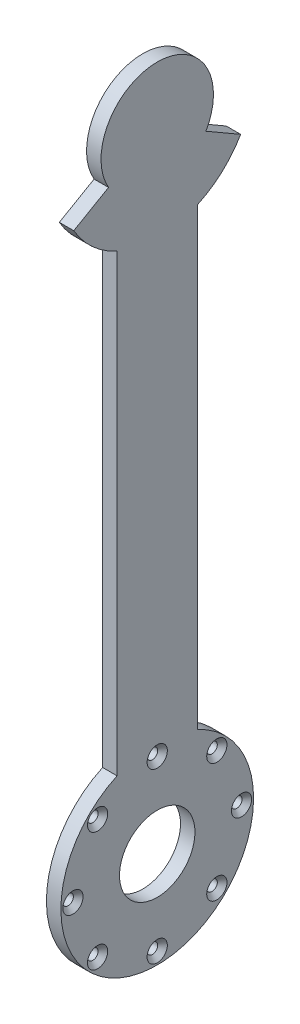
from build123d import *

# Parameters (mm, degrees)
SKETCH1_R                                           = 23.5
BOSS_EXTRUDE1_DEPTH                                 = 9
CSK_FOR_M6_COUNTERSUNK_FLAT_HEAD_SCREW1_D           = 6.6
CSK_FOR_M6_COUNTERSUNK_FLAT_HEAD_SCREW1_CSINK_D     = 12.6
CSK_FOR_M6_COUNTERSUNK_FLAT_HEAD_SCREW1_CSINK_ANGLE = 90


with BuildPart() as part:
    # Sketch1 → Boss-Extrude1 (new body)
    with BuildSketch(Plane(origin=(0, 0, 0), x_dir=(0, 0, -1), z_dir=(1, 0, 0))):
        with BuildLine():
            Line((-30.310889132, 178.5), (-51.961524227, 166))
            ThreePointArc((-51.961524227, 166), (-40.390167668, 151.630704809), (-25, 141.456439427))
            Line((-25, 141.456439427), (-25, -141.456439427))
            ThreePointArc((-25, -141.456439427), (0, -256), (25, -141.456439427))
            Line((25, -141.456439427), (25, 141.456439427))
            ThreePointArc((25, 141.456439427), (40.390167668, 151.630704809), (51.961524227, 166))
            Line((51.961524227, 166), (30.310889132, 178.5))
            ThreePointArc((30.310889132, 178.5), (0, 231), (-30.310889132, 178.5))
        make_face()
        with Locations((0, -196)):
            Circle(SKETCH1_R, mode=Mode.SUBTRACT)
    extrude(amount=BOSS_EXTRUDE1_DEPTH)

    # CSK for M6 Countersunk Flat Head Screw1 (through all)
    with Locations(Plane(origin=(9, 0, 0), x_dir=(0, 0, -1), z_dir=(1, 0, 0))):
        with Locations((-37.123106012, -158.876893988), (0, -143.5), (37.123106012, -158.876893988), (52.5, -196), (37.123106012, -233.123106012), (0, -248.5), (-37.123106012, -233.123106012), (-52.5, -196)):
            CounterSinkHole(CSK_FOR_M6_COUNTERSUNK_FLAT_HEAD_SCREW1_D / 2, CSK_FOR_M6_COUNTERSUNK_FLAT_HEAD_SCREW1_CSINK_D / 2, counter_sink_angle=CSK_FOR_M6_COUNTERSUNK_FLAT_HEAD_SCREW1_CSINK_ANGLE)


solid = part.part
